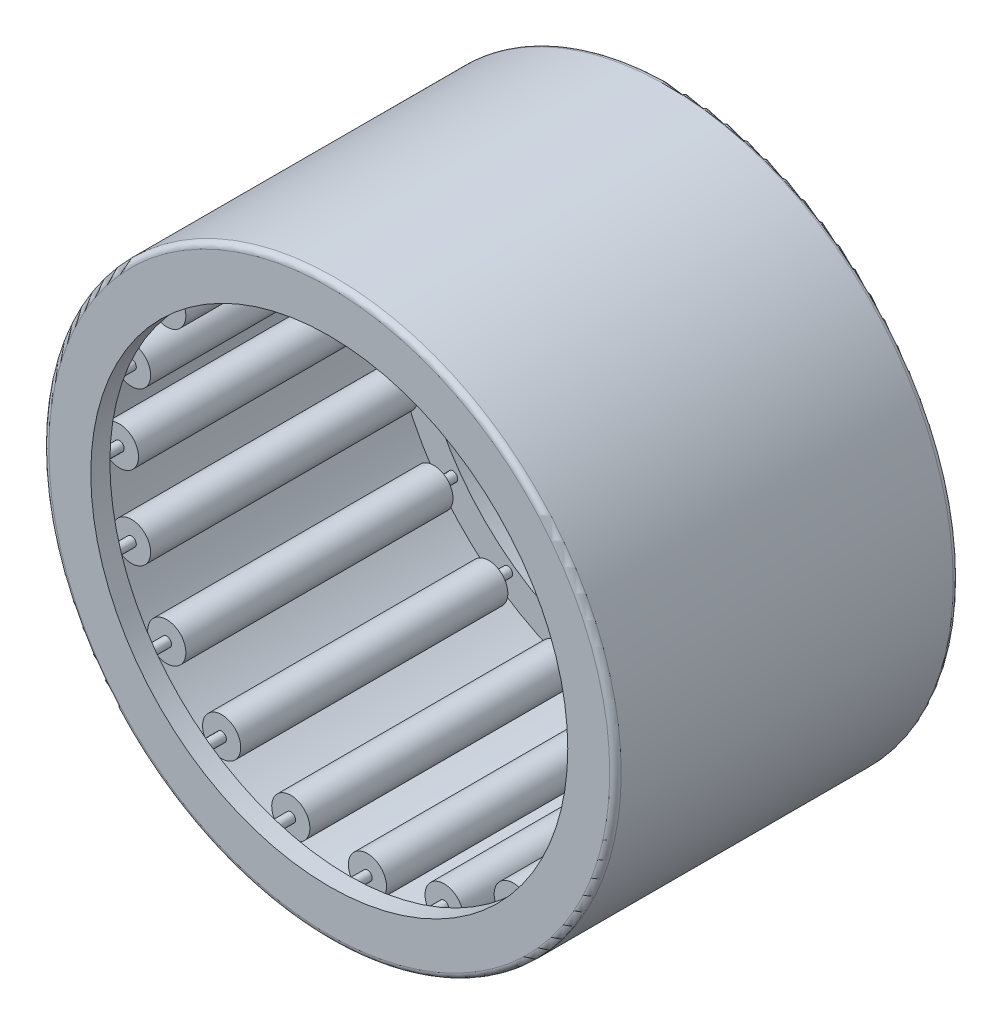
from build123d import *

# Parameters (mm, degrees)
SKETCH2_W         = 14.816666666
SKETCH2_H         = 0.79375
SKETCH3_W         = 16.933333334
SKETCH3_H         = 0.264583334
CIRPATTERN1_COUNT = 20
CIRPATTERN1_ANGLE = 342
FILLET1_R         = 0.3175


with BuildPart() as part:
    # Sketch1 → Revolve1 (revolve)
    with BuildSketch(Plane(origin=(0, 0, 0), x_dir=(0, 0, -1), z_dir=(1, 0, 0))):
        Polygon((-9.525, 15.875), (9.525, 15.875), (9.525, 13.229166667), (8.466666667, 13.229166667), (8.466666667, 14.816666667), (-8.466666667, 14.816666667), (-8.466666667, 13.229166667), (-9.525, 13.229166667), align=None)
    revolve(axis=Axis((0, 0, 9.525), (0, 0, -1)))

    # Fillet1
    fillet1_edges = [part.edges().sort_by_distance(p)[0] for p in [
        (0, -15.875, 9.525),
        (0, -15.875, -9.525),
    ]]
    fillet(fillet1_edges, radius=FILLET1_R)


with BuildPart() as body_2:
    # Sketch2 → Revolve2 (revolve)
    with BuildSketch(Plane(origin=(0, 0, 0), x_dir=(0, 0, -1), z_dir=(1, 0, 0))):
        with Locations((0, 14.419791667)):
            Rectangle(SKETCH2_W, SKETCH2_H)
    revolve(axis=Axis((0, 13.758333333, 7.408333333), (0, 0, -1)))


with BuildPart() as body_3:
    # Sketch3 → Revolve3 (revolve)
    with BuildSketch(Plane(origin=(0, 0, 0), x_dir=(0, 0, -1), z_dir=(1, 0, 0))):
        with Locations((0, 13.890625)):
            Rectangle(SKETCH3_W, SKETCH3_H)
    revolve(axis=Axis((0, 13.758333333, 8.466666667), (0, 0, -1)))


with BuildPart() as cirpattern1_1:
    # CirPattern1: pattern copy
    add(body_2.part.rotate(Axis((0, 0, -9.525), (0, 0, 1)), 1 * CIRPATTERN1_ANGLE / (CIRPATTERN1_COUNT - 1)))


with BuildPart() as cirpattern1_2:
    # CirPattern1: pattern copy
    add(body_2.part.rotate(Axis((0, 0, -9.525), (0, 0, 1)), 2 * CIRPATTERN1_ANGLE / (CIRPATTERN1_COUNT - 1)))


with BuildPart() as cirpattern1_3:
    # CirPattern1: pattern copy
    add(body_2.part.rotate(Axis((0, 0, -9.525), (0, 0, 1)), 3 * CIRPATTERN1_ANGLE / (CIRPATTERN1_COUNT - 1)))


with BuildPart() as cirpattern1_4:
    # CirPattern1: pattern copy
    add(body_2.part.rotate(Axis((0, 0, -9.525), (0, 0, 1)), 4 * CIRPATTERN1_ANGLE / (CIRPATTERN1_COUNT - 1)))


with BuildPart() as cirpattern1_5:
    # CirPattern1: pattern copy
    add(body_2.part.rotate(Axis((0, 0, -9.525), (0, 0, 1)), 5 * CIRPATTERN1_ANGLE / (CIRPATTERN1_COUNT - 1)))


with BuildPart() as cirpattern1_6:
    # CirPattern1: pattern copy
    add(body_2.part.rotate(Axis((0, 0, -9.525), (0, 0, 1)), 6 * CIRPATTERN1_ANGLE / (CIRPATTERN1_COUNT - 1)))


with BuildPart() as cirpattern1_7:
    # CirPattern1: pattern copy
    add(body_2.part.rotate(Axis((0, 0, -9.525), (0, 0, 1)), 7 * CIRPATTERN1_ANGLE / (CIRPATTERN1_COUNT - 1)))


with BuildPart() as cirpattern1_8:
    # CirPattern1: pattern copy
    add(body_2.part.rotate(Axis((0, 0, -9.525), (0, 0, 1)), 8 * CIRPATTERN1_ANGLE / (CIRPATTERN1_COUNT - 1)))


with BuildPart() as cirpattern1_9:
    # CirPattern1: pattern copy
    add(body_2.part.rotate(Axis((0, 0, -9.525), (0, 0, 1)), 9 * CIRPATTERN1_ANGLE / (CIRPATTERN1_COUNT - 1)))


with BuildPart() as cirpattern1_10:
    # CirPattern1: pattern copy
    add(body_2.part.rotate(Axis((0, 0, -9.525), (0, 0, 1)), 10 * CIRPATTERN1_ANGLE / (CIRPATTERN1_COUNT - 1)))


with BuildPart() as cirpattern1_11:
    # CirPattern1: pattern copy
    add(body_2.part.rotate(Axis((0, 0, -9.525), (0, 0, 1)), 11 * CIRPATTERN1_ANGLE / (CIRPATTERN1_COUNT - 1)))


with BuildPart() as cirpattern1_12:
    # CirPattern1: pattern copy
    add(body_2.part.rotate(Axis((0, 0, -9.525), (0, 0, 1)), 12 * CIRPATTERN1_ANGLE / (CIRPATTERN1_COUNT - 1)))


with BuildPart() as cirpattern1_13:
    # CirPattern1: pattern copy
    add(body_2.part.rotate(Axis((0, 0, -9.525), (0, 0, 1)), 13 * CIRPATTERN1_ANGLE / (CIRPATTERN1_COUNT - 1)))


with BuildPart() as cirpattern1_14:
    # CirPattern1: pattern copy
    add(body_2.part.rotate(Axis((0, 0, -9.525), (0, 0, 1)), 14 * CIRPATTERN1_ANGLE / (CIRPATTERN1_COUNT - 1)))


with BuildPart() as cirpattern1_15:
    # CirPattern1: pattern copy
    add(body_2.part.rotate(Axis((0, 0, -9.525), (0, 0, 1)), 15 * CIRPATTERN1_ANGLE / (CIRPATTERN1_COUNT - 1)))


with BuildPart() as cirpattern1_16:
    # CirPattern1: pattern copy
    add(body_2.part.rotate(Axis((0, 0, -9.525), (0, 0, 1)), 16 * CIRPATTERN1_ANGLE / (CIRPATTERN1_COUNT - 1)))


with BuildPart() as cirpattern1_17:
    # CirPattern1: pattern copy
    add(body_2.part.rotate(Axis((0, 0, -9.525), (0, 0, 1)), 17 * CIRPATTERN1_ANGLE / (CIRPATTERN1_COUNT - 1)))


with BuildPart() as cirpattern1_18:
    # CirPattern1: pattern copy
    add(body_2.part.rotate(Axis((0, 0, -9.525), (0, 0, 1)), 18 * CIRPATTERN1_ANGLE / (CIRPATTERN1_COUNT - 1)))


with BuildPart() as cirpattern1_19:
    # CirPattern1: pattern copy
    add(body_2.part.rotate(Axis((0, 0, -9.525), (0, 0, 1)), 19 * CIRPATTERN1_ANGLE / (CIRPATTERN1_COUNT - 1)))


with BuildPart() as cirpattern1_20:
    # CirPattern1: pattern copy
    add(body_3.part.rotate(Axis((0, 0, -9.525), (0, 0, 1)), 1 * CIRPATTERN1_ANGLE / (CIRPATTERN1_COUNT - 1)))


with BuildPart() as cirpattern1_21:
    # CirPattern1: pattern copy
    add(body_3.part.rotate(Axis((0, 0, -9.525), (0, 0, 1)), 2 * CIRPATTERN1_ANGLE / (CIRPATTERN1_COUNT - 1)))


with BuildPart() as cirpattern1_22:
    # CirPattern1: pattern copy
    add(body_3.part.rotate(Axis((0, 0, -9.525), (0, 0, 1)), 3 * CIRPATTERN1_ANGLE / (CIRPATTERN1_COUNT - 1)))


with BuildPart() as cirpattern1_23:
    # CirPattern1: pattern copy
    add(body_3.part.rotate(Axis((0, 0, -9.525), (0, 0, 1)), 4 * CIRPATTERN1_ANGLE / (CIRPATTERN1_COUNT - 1)))


with BuildPart() as cirpattern1_24:
    # CirPattern1: pattern copy
    add(body_3.part.rotate(Axis((0, 0, -9.525), (0, 0, 1)), 5 * CIRPATTERN1_ANGLE / (CIRPATTERN1_COUNT - 1)))


with BuildPart() as cirpattern1_25:
    # CirPattern1: pattern copy
    add(body_3.part.rotate(Axis((0, 0, -9.525), (0, 0, 1)), 6 * CIRPATTERN1_ANGLE / (CIRPATTERN1_COUNT - 1)))


with BuildPart() as cirpattern1_26:
    # CirPattern1: pattern copy
    add(body_3.part.rotate(Axis((0, 0, -9.525), (0, 0, 1)), 7 * CIRPATTERN1_ANGLE / (CIRPATTERN1_COUNT - 1)))


with BuildPart() as cirpattern1_27:
    # CirPattern1: pattern copy
    add(body_3.part.rotate(Axis((0, 0, -9.525), (0, 0, 1)), 8 * CIRPATTERN1_ANGLE / (CIRPATTERN1_COUNT - 1)))


with BuildPart() as cirpattern1_28:
    # CirPattern1: pattern copy
    add(body_3.part.rotate(Axis((0, 0, -9.525), (0, 0, 1)), 9 * CIRPATTERN1_ANGLE / (CIRPATTERN1_COUNT - 1)))


with BuildPart() as cirpattern1_29:
    # CirPattern1: pattern copy
    add(body_3.part.rotate(Axis((0, 0, -9.525), (0, 0, 1)), 10 * CIRPATTERN1_ANGLE / (CIRPATTERN1_COUNT - 1)))


with BuildPart() as cirpattern1_30:
    # CirPattern1: pattern copy
    add(body_3.part.rotate(Axis((0, 0, -9.525), (0, 0, 1)), 11 * CIRPATTERN1_ANGLE / (CIRPATTERN1_COUNT - 1)))


with BuildPart() as cirpattern1_31:
    # CirPattern1: pattern copy
    add(body_3.part.rotate(Axis((0, 0, -9.525), (0, 0, 1)), 12 * CIRPATTERN1_ANGLE / (CIRPATTERN1_COUNT - 1)))


with BuildPart() as cirpattern1_32:
    # CirPattern1: pattern copy
    add(body_3.part.rotate(Axis((0, 0, -9.525), (0, 0, 1)), 13 * CIRPATTERN1_ANGLE / (CIRPATTERN1_COUNT - 1)))


with BuildPart() as cirpattern1_33:
    # CirPattern1: pattern copy
    add(body_3.part.rotate(Axis((0, 0, -9.525), (0, 0, 1)), 14 * CIRPATTERN1_ANGLE / (CIRPATTERN1_COUNT - 1)))


with BuildPart() as cirpattern1_34:
    # CirPattern1: pattern copy
    add(body_3.part.rotate(Axis((0, 0, -9.525), (0, 0, 1)), 15 * CIRPATTERN1_ANGLE / (CIRPATTERN1_COUNT - 1)))


with BuildPart() as cirpattern1_35:
    # CirPattern1: pattern copy
    add(body_3.part.rotate(Axis((0, 0, -9.525), (0, 0, 1)), 16 * CIRPATTERN1_ANGLE / (CIRPATTERN1_COUNT - 1)))


with BuildPart() as cirpattern1_36:
    # CirPattern1: pattern copy
    add(body_3.part.rotate(Axis((0, 0, -9.525), (0, 0, 1)), 17 * CIRPATTERN1_ANGLE / (CIRPATTERN1_COUNT - 1)))


with BuildPart() as cirpattern1_37:
    # CirPattern1: pattern copy
    add(body_3.part.rotate(Axis((0, 0, -9.525), (0, 0, 1)), 18 * CIRPATTERN1_ANGLE / (CIRPATTERN1_COUNT - 1)))


with BuildPart() as cirpattern1_38:
    # CirPattern1: pattern copy
    add(body_3.part.rotate(Axis((0, 0, -9.525), (0, 0, 1)), 19 * CIRPATTERN1_ANGLE / (CIRPATTERN1_COUNT - 1)))


solid = Compound([part.part, body_2.part, body_3.part, cirpattern1_1.part, cirpattern1_2.part, cirpattern1_3.part, cirpattern1_4.part, cirpattern1_5.part, cirpattern1_6.part, cirpattern1_7.part, cirpattern1_8.part, cirpattern1_9.part, cirpattern1_10.part, cirpattern1_11.part, cirpattern1_12.part, cirpattern1_13.part, cirpattern1_14.part, cirpattern1_15.part, cirpattern1_16.part, cirpattern1_17.part, cirpattern1_18.part, cirpattern1_19.part, cirpattern1_20.part, cirpattern1_21.part, cirpattern1_22.part, cirpattern1_23.part, cirpattern1_24.part, cirpattern1_25.part, cirpattern1_26.part, cirpattern1_27.part, cirpattern1_28.part, cirpattern1_29.part, cirpattern1_30.part, cirpattern1_31.part, cirpattern1_32.part, cirpattern1_33.part, cirpattern1_34.part, cirpattern1_35.part, cirpattern1_36.part, cirpattern1_37.part, cirpattern1_38.part])
